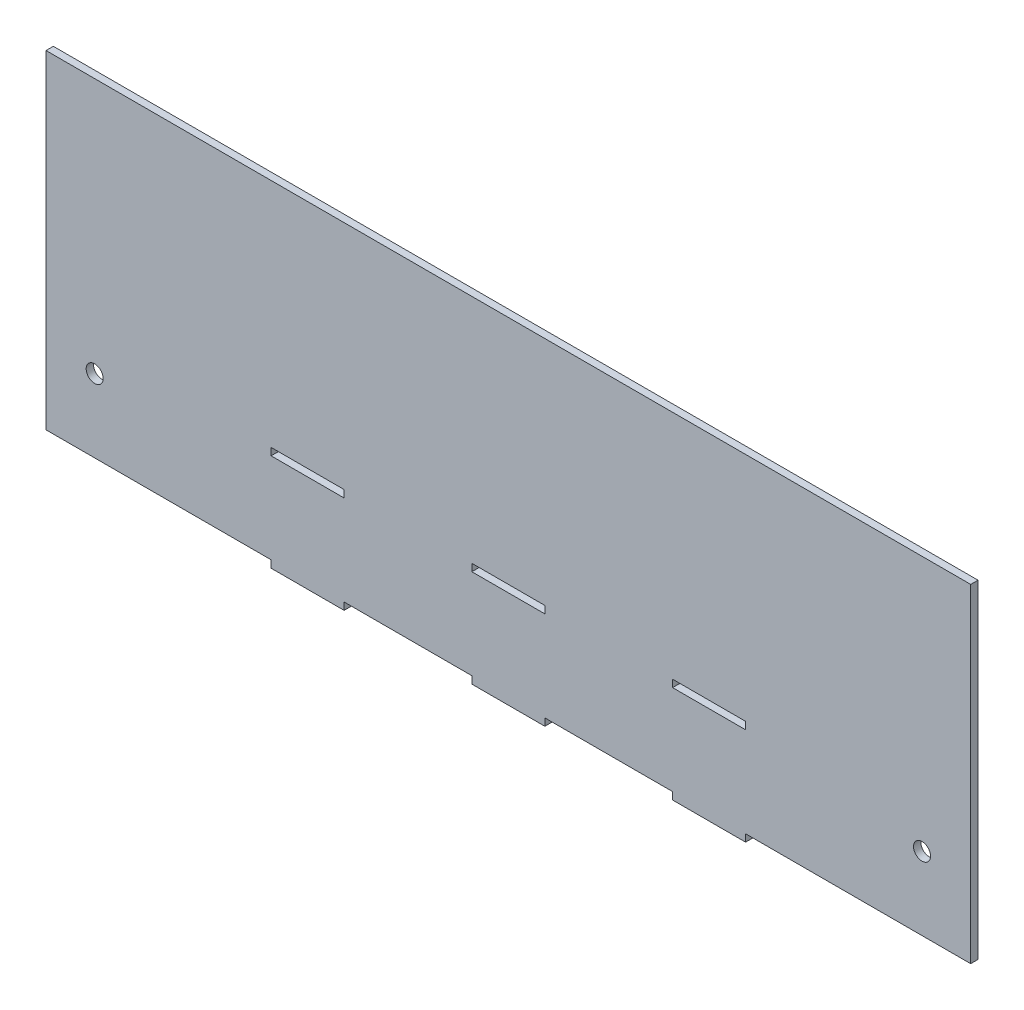
from build123d import *

# Parameters (mm, degrees)
CROQUIS1_R              = 3.5
CROQUIS1_W              = 30
CROQUIS1_H              = 3
SALIENTE_EXTRUIR1_DEPTH = 3


with BuildPart() as part:
    # Croquis1 → Saliente-Extruir1 (new body)
    with BuildSketch(Plane.XY):
        Polygon((-190, -67.5), (-97.5, -67.5), (-97.5, -70.5), (-67.5, -70.5), (-67.5, -67.5), (-15, -67.5), (-15, -70.5), (15, -70.5), (15, -67.5), (67.5, -67.5), (67.5, -70.5), (97.5, -70.5), (97.5, -67.5), (190, -67.5), (190, 67.5), (-190, 67.5), align=None)
        with Locations((-170, -37.5)):
            Circle(CROQUIS1_R, mode=Mode.SUBTRACT)
        with Locations((170, -37.5)):
            Circle(CROQUIS1_R, mode=Mode.SUBTRACT)
        with Locations((82.5, -29)):
            Rectangle(CROQUIS1_W, CROQUIS1_H, mode=Mode.SUBTRACT)
        with Locations((0, -29)):
            Rectangle(CROQUIS1_W, CROQUIS1_H, mode=Mode.SUBTRACT)
        with Locations((-82.5, -29)):
            Rectangle(CROQUIS1_W, CROQUIS1_H, mode=Mode.SUBTRACT)
    extrude(amount=SALIENTE_EXTRUIR1_DEPTH)


solid = part.part
